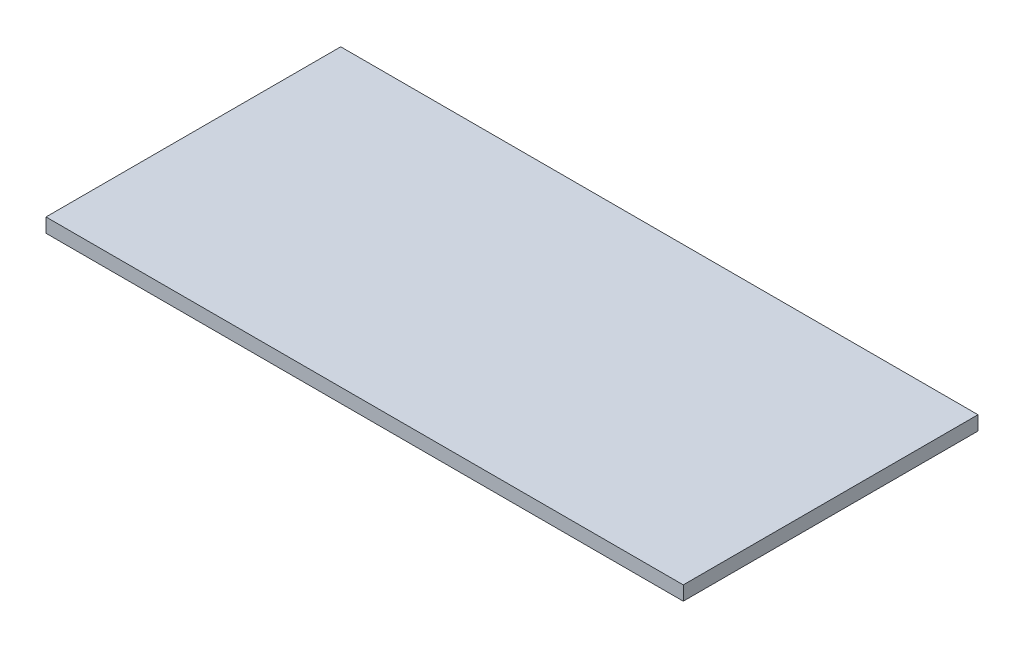
from build123d import *

# Parameters (mm, degrees)
SKETCH2_W           = 1143
SKETCH2_H           = 528.6375
BOSS_EXTRUDE1_DEPTH = 25.4


with BuildPart() as part:
    # Sketch2 → Boss-Extrude1 (new body)
    with BuildSketch(Plane(origin=(0, 0, 0), x_dir=(1, 0, 0), z_dir=(0, 1, 0))):
        with Locations((571.5, 264.31875)):
            Rectangle(SKETCH2_W, SKETCH2_H)
    extrude(amount=BOSS_EXTRUDE1_DEPTH)


solid = part.part
